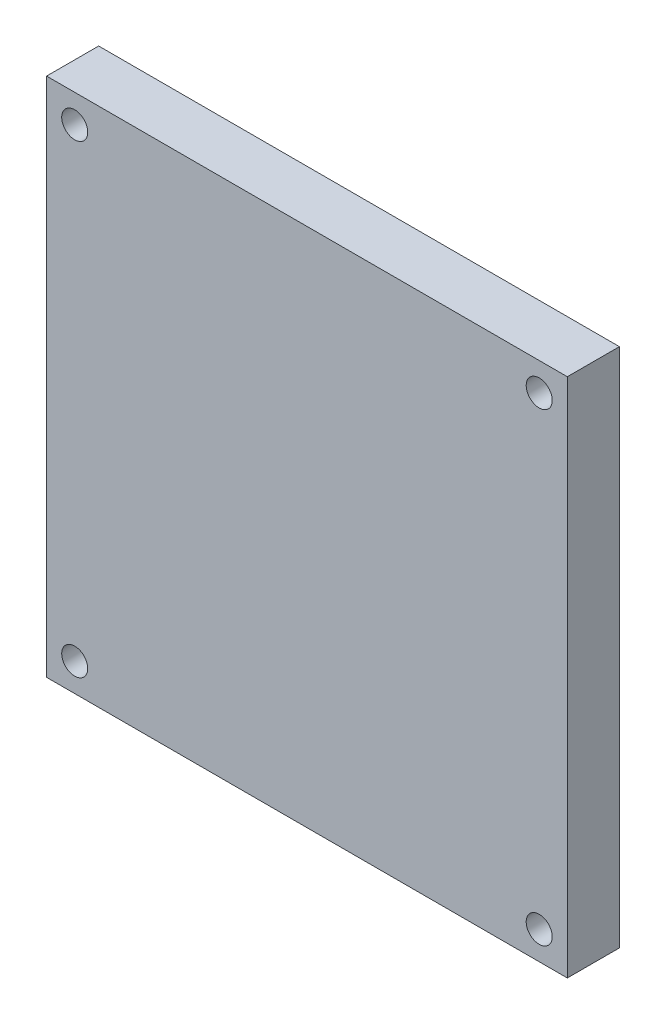
from build123d import *

# Parameters (mm, degrees)
SKETCH1_W           = 50
SKETCH1_H           = 50
SKETCH1_R           = 1.25
BOSS_EXTRUDE1_DEPTH = 5


with BuildPart() as part:
    # Sketch1 → Boss-Extrude1 (new body)
    with BuildSketch(Plane.XY):
        with Locations((-25, 25)):
            Rectangle(SKETCH1_W, SKETCH1_H)
        with Locations((-47.3, 47.3)):
            Circle(SKETCH1_R, mode=Mode.SUBTRACT)
        with Locations((-2.7, 47.3)):
            Circle(SKETCH1_R, mode=Mode.SUBTRACT)
        with Locations((-47.3, 2.7)):
            Circle(SKETCH1_R, mode=Mode.SUBTRACT)
        with Locations((-2.7, 2.7)):
            Circle(SKETCH1_R, mode=Mode.SUBTRACT)
    extrude(amount=BOSS_EXTRUDE1_DEPTH)


solid = part.part
